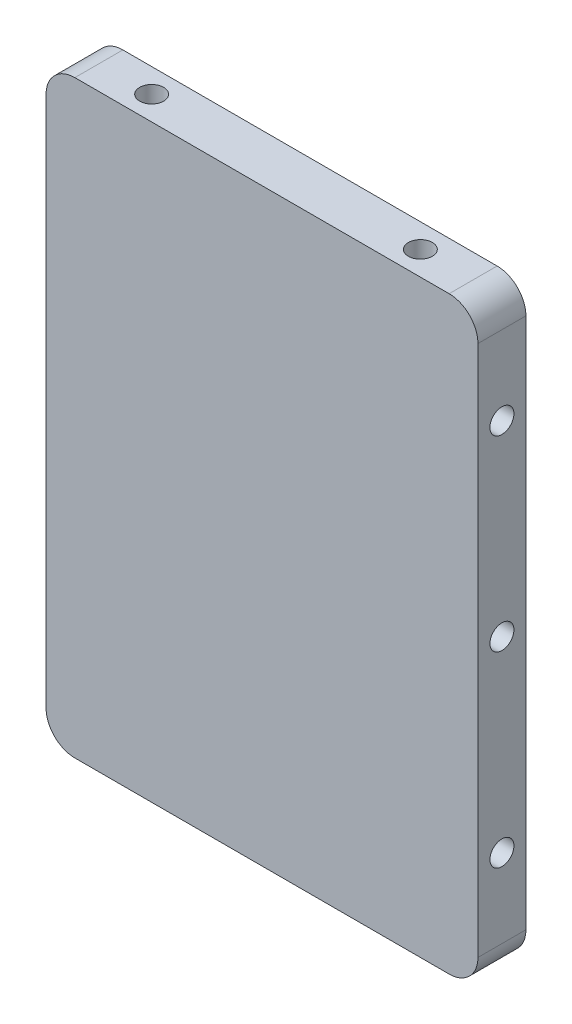
from build123d import *

# Parameters (mm, degrees)
SKETCH_1_W         = 45
SKETCH_1_H         = 61.4
EXTRUDE_1_DEPTH    = 5
HOLE_WIZARD_M3_3_D = 2.5
HOLE_WIZARD_M3_4_D = 2.5
FILLET_1_R         = 3


with BuildPart() as part:
    # 草图1 → 凸台-拉伸1 (new body)
    with BuildSketch(Plane.XY):
        Rectangle(SKETCH_1_W, SKETCH_1_H)
    extrude(amount=EXTRUDE_1_DEPTH)

    # 草图3 → M3 螺纹孔1 (revolve, cut)
    with BuildSketch(Plane(origin=(-22.5, 0, 2.5), x_dir=(0, 0, 1), z_dir=(0, 1, 0))):
        Polygon((0, 0), (0, 5.751075774), (1.25, 5), (1.25, 0), align=None)
    hole_wizard_m3_1 = revolve(axis=Axis((-28.85, 0, 2.5), (1, 0, 0)), mode=Mode.SUBTRACT)

    # 草图5 → M3 螺纹孔2 (revolve, cut)
    with BuildSketch(Plane(origin=(-22.5, 19.5, 2.5), x_dir=(0, 0, 1), z_dir=(0, 1, 0))):
        Polygon((0, 0), (0, 5.751075774), (1.25, 5), (1.25, 0), align=None)
    hole_wizard_m3_2 = revolve(axis=Axis((-28.85, 19.5, 2.5), (1, 0, 0)), mode=Mode.SUBTRACT)

    # 镜向1: M3 螺纹孔2 across plane
    add(hole_wizard_m3_2.mirror(Plane.ZX), mode=Mode.SUBTRACT)

    # M3 螺纹孔3 (through all)
    with Locations(Plane(origin=(0, -30.7, 0), x_dir=(-1, 0, 0), z_dir=(0, -1, 0))):
        with Locations((-14, -2.5)):
            hole_wizard_m3_3 = Hole(HOLE_WIZARD_M3_3_D / 2)

    # 镜向2: M3 螺纹孔3 across plane
    add(hole_wizard_m3_3.mirror(Plane(origin=(0, 0, 0), x_dir=(0, 0, 1), z_dir=(1, 0, 0))), mode=Mode.SUBTRACT)

    # 镜向3: M3 螺纹孔2, M3 螺纹孔1 across plane
    add(hole_wizard_m3_2.mirror(Plane(origin=(0, 0, 0), x_dir=(0, 0, 1), z_dir=(1, 0, 0))), mode=Mode.SUBTRACT)
    add(hole_wizard_m3_1.mirror(Plane(origin=(0, 0, 0), x_dir=(0, 0, 1), z_dir=(1, 0, 0))), mode=Mode.SUBTRACT)

    # 镜向3 copy 1 sketch → 镜向3 copy 1 (revolve, cut)
    with BuildSketch(Plane(origin=(22.5, -19.5, 2.5), x_dir=(0, 0, 1), z_dir=(0, -1, 0))):
        Polygon((0, 0), (0, 5.751075774), (1.25, 5), (1.25, 0), align=None)
    revolve(axis=Axis((28.85, -19.5, 2.5), (-1, 0, 0)), mode=Mode.SUBTRACT)

    # M3 螺纹孔4 (through all)
    with Locations(Plane(origin=(0, 30.7, 0), x_dir=(1, 0, 0), z_dir=(0, 1, 0))):
        with Locations((-14, -2.5), (14, -2.5)):
            Hole(HOLE_WIZARD_M3_4_D / 2)

    # 圆角1
    fillet_1_edges = [part.edges().sort_by_distance(p)[0] for p in [
        (22.5, -30.7, 2.5),
        (-22.5, -30.7, 2.5),
        (-22.5, 30.7, 2.5),
        (22.5, 30.7, 2.5),
    ]]
    fillet(fillet_1_edges, radius=FILLET_1_R)


solid = part.part
